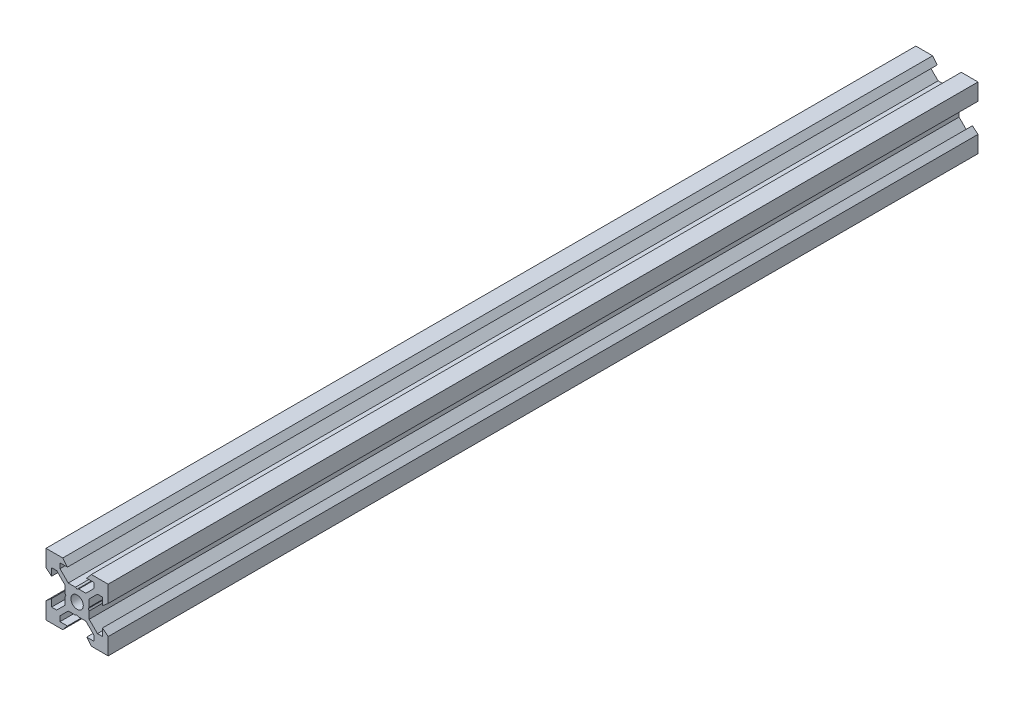
from build123d import *

# Parameters (mm, degrees)
SKETCH1_R           = 2
BOSS_EXTRUDE1_DEPTH = 140


with BuildPart() as part:
    # Sketch1 → Boss-Extrude1 (new body, symmetric)
    with BuildSketch(Plane.XY):
        Polygon((10, 10), (10, 4.610379336), (8.2, 3.1), (8.2, 5.5), (6.560660172, 5.5), (3.9, 2.839339828), (3.9, 0.519615242), (3.6, 0), (3.9, -0.519615242), (3.9, -2.839339828), (6.560660172, -5.5), (8.2, -5.5), (8.2, -3.1), (10, -4.610379336), (10, -10), (4.610379336, -10), (3.1, -8.2), (5.5, -8.2), (5.5, -6.560660172), (2.839339828, -3.9), (0.519615242, -3.9), (0, -3.6), (-0.519615242, -3.9), (-2.839339828, -3.9), (-5.5, -6.560660172), (-5.5, -8.2), (-3.1, -8.2), (-4.610379336, -10), (-10, -10), (-10, -4.610379336), (-8.2, -3.1), (-8.2, -5.5), (-6.560660172, -5.5), (-3.9, -2.839339828), (-3.9, -0.519615242), (-3.6, 0), (-3.9, 0.519615242), (-3.9, 2.839339828), (-6.560660172, 5.5), (-8.2, 5.5), (-8.2, 3.1), (-10, 4.610379336), (-10, 10), (-4.610379336, 10), (-3.1, 8.2), (-5.5, 8.2), (-5.5, 6.560660172), (-2.839339828, 3.9), (-0.519615242, 3.9), (0, 3.6), (0.519615242, 3.9), (2.839339828, 3.9), (5.5, 6.560660172), (5.5, 8.2), (3.1, 8.2), (4.610379336, 10), align=None)
        Circle(SKETCH1_R, mode=Mode.SUBTRACT)
    extrude(amount=BOSS_EXTRUDE1_DEPTH, both=True)


solid = part.part
